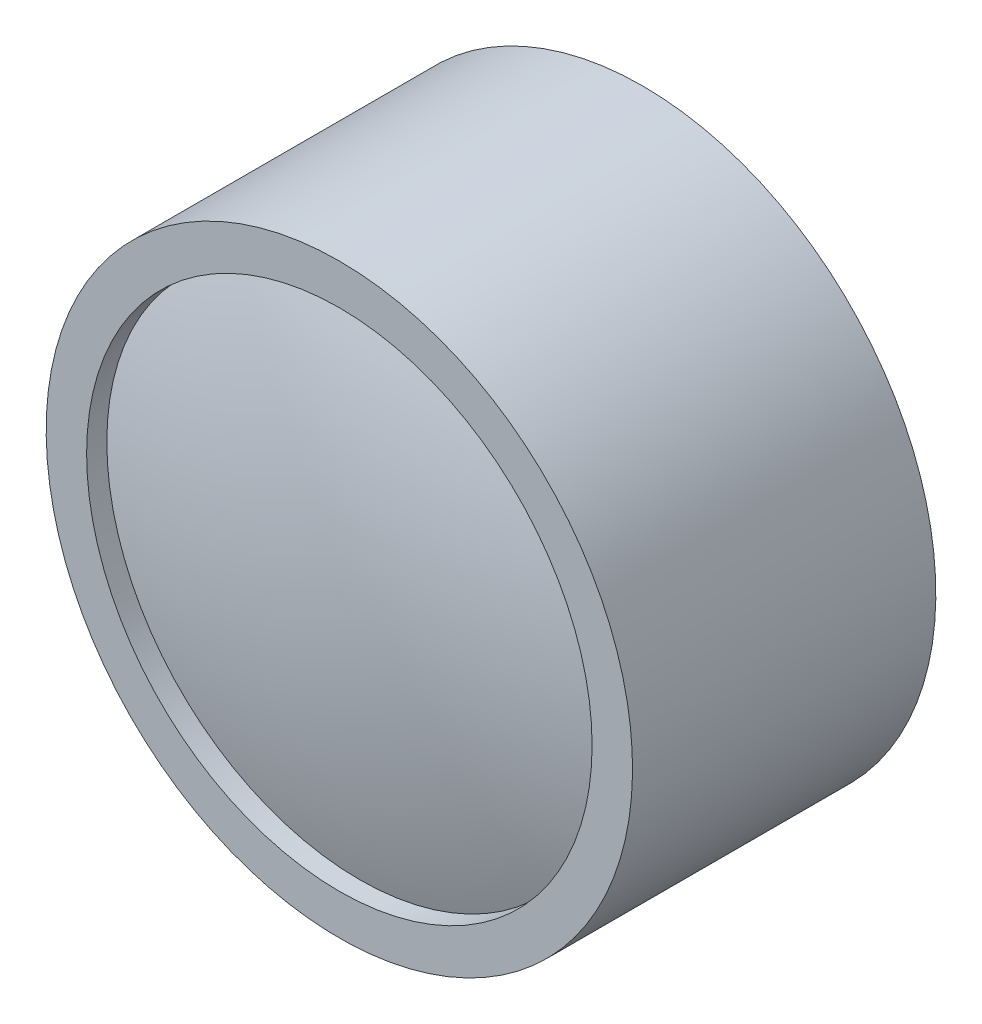
from build123d import *


with BuildPart() as part:
    # Sketch1 → Revolve1 (revolve)
    with BuildSketch(Plane(origin=(0, 0, 0), x_dir=(0, 0, -1), z_dir=(1, 0, 0))):
        with BuildLine():
            Line((0, 0), (0, 14.5))
            Line((0, 14.5), (-15, 14.5))
            Line((-15, 14.5), (-15, 12.5))
            Line((-15, 12.5), (-14, 12.5))
            ThreePointArc((-14, 12.5), (-15.496840316, 6.329494451), (-16, 0))
            Line((-16, 0), (0, 0))
        make_face()
    revolve(axis=Axis((0, 0, 0), (0, 0, 1)))


solid = part.part
